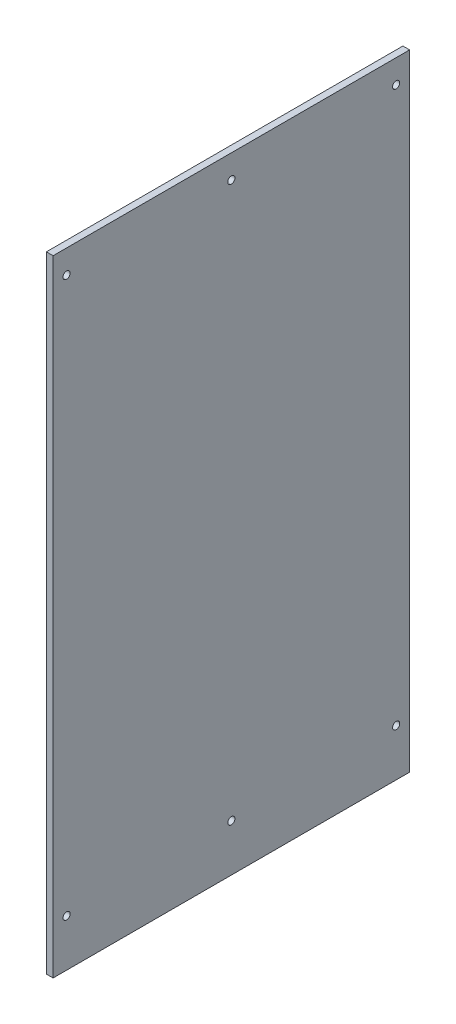
from build123d import *

# Parameters (mm, degrees)
SKETCH1_W           = 336.55
SKETCH1_H           = 590.55
BOSS_EXTRUDE1_DEPTH = 6.35
SKETCH2_R           = 3.3782
CUT_EXTRUDE1_DEPTH  = 6.35
LPATTERN1_COUNT     = 3
LPATTERN1_PITCH     = 155.575


with BuildPart() as part:
    # Sketch1 → Boss-Extrude1 (new body)
    with BuildSketch(Plane(origin=(0, 0, 0), x_dir=(0, 0, -1), z_dir=(1, 0, 0))):
        with Locations((168.275, 295.275)):
            Rectangle(SKETCH1_W, SKETCH1_H)
    extrude(amount=BOSS_EXTRUDE1_DEPTH)

    # Sketch2 → Cut-Extrude1 (cut)
    with BuildSketch(Plane(origin=(6.35, 0, 0), x_dir=(0, 0, -1), z_dir=(1, 0, 0))):
        with Locations((323.85, 568.325)):
            Circle(SKETCH2_R)
        with Locations((323.85, 44.45)):
            Circle(SKETCH2_R)
    cut_extrude1 = extrude(amount=-CUT_EXTRUDE1_DEPTH, mode=Mode.SUBTRACT)

    # LPattern1: Cut-Extrude1 ×3
    with Locations(*[(0, 0, i * LPATTERN1_PITCH) for i in range(1, LPATTERN1_COUNT)]):
        add(cut_extrude1, mode=Mode.SUBTRACT)


solid = part.part
